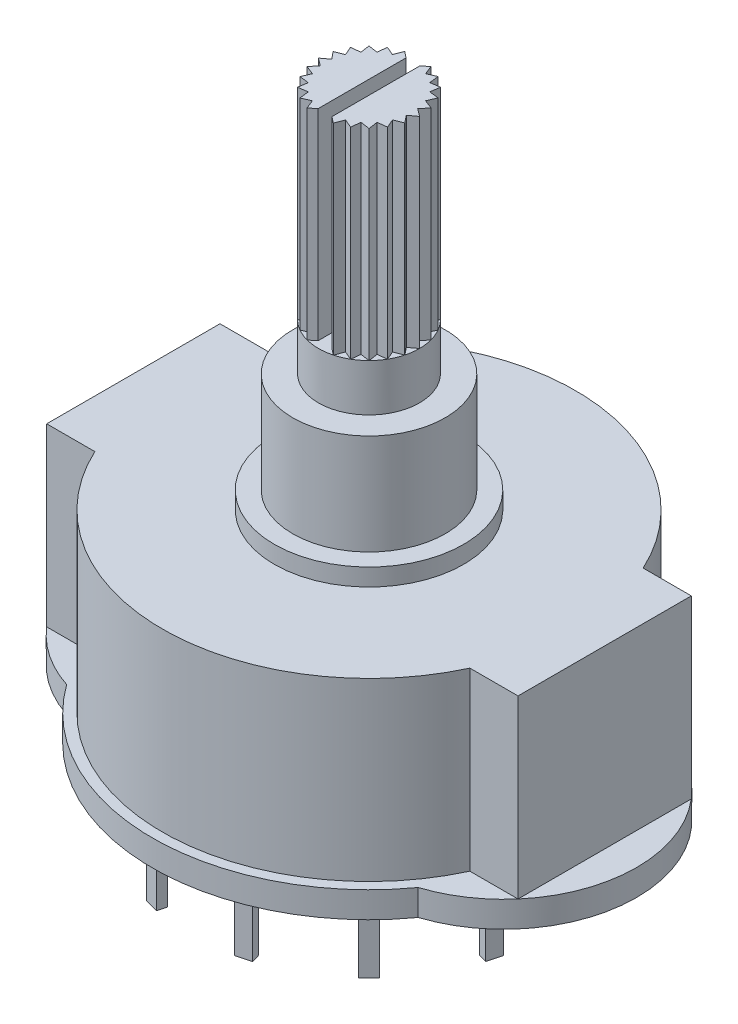
from build123d import *

# Parameters (mm, degrees)
BOSS_EXTRUDE1_DEPTH = 10.15
BOSS_EXTRUDE2_DEPTH = 1.5
SKETCH4_R           = 5.46
BOSS_EXTRUDE3_DEPTH = 1
SKETCH5_R           = 4.4
BOSS_EXTRUDE4_DEPTH = 5.8
SKETCH6_R           = 2.915
BOSS_EXTRUDE5_DEPTH = 14.32
BOSS_EXTRUDE6_DEPTH = 4.5
SKETCH8_W           = 0.5
SKETCH8_H           = 0.85
BOSS_EXTRUDE7_DEPTH = 4.5
SKETCH9_R           = 2.8
CUT_EXTRUDE1_DEPTH  = 4.5
CUT_EXTRUDE3_DEPTH  = 11.6
SKETCH10_W          = 0.8
SKETCH10_H          = 6.735502357
CUT_EXTRUDE2_DEPTH  = 11.6


with BuildPart() as part:
    # Sketch2 → Boss-Extrude1 (new body)
    with BuildSketch(Plane(origin=(0, 0, 0), x_dir=(1, 0, 0), z_dir=(0, 1, 0))):
        with BuildLine():
            Line((-13.6, 5), (-13.6, -5))
            Line((-13.6, -5), (-10.820646931, -5))
            ThreePointArc((-10.820646931, -5), (0, -11.92), (10.820646931, -5))
            Line((10.820646931, -5), (13.6, -5))
            Line((13.6, -5), (13.6, 5))
            Line((13.6, 5), (10.820646931, 5))
            ThreePointArc((10.820646931, 5), (0, 11.92), (-10.820646931, 5))
            Line((-10.820646931, 5), (-13.6, 5))
        make_face()
    extrude(amount=BOSS_EXTRUDE1_DEPTH)

    # Sketch3 → Boss-Extrude2 (add)
    with BuildSketch(Plane.XZ):
        with BuildLine():
            ThreePointArc((-10.142976429, -7.305479393), (0, -12.5), (10.142976429, -7.305479393))
            ThreePointArc((10.142976429, -7.305479393), (15.45, 0), (10.142976429, 7.305479393))
            ThreePointArc((10.142976429, 7.305479393), (0, 12.5), (-10.142976429, 7.305479393))
            ThreePointArc((-10.142976429, 7.305479393), (-15.45, 0), (-10.142976429, -7.305479393))
        make_face()
    extrude(amount=BOSS_EXTRUDE2_DEPTH)

    # Sketch4 → Boss-Extrude3 (add)
    with BuildSketch(Plane(origin=(0, 10.15, 0), x_dir=(1, 0, 0), z_dir=(0, 1, 0))):
        Circle(SKETCH4_R)
    extrude(amount=BOSS_EXTRUDE3_DEPTH)

    # Sketch5 → Boss-Extrude4 (add)
    with BuildSketch(Plane(origin=(0, 11.15, 0), x_dir=(1, 0, 0), z_dir=(0, 1, 0))):
        Circle(SKETCH5_R)
    extrude(amount=BOSS_EXTRUDE4_DEPTH)

    # Sketch6 → Boss-Extrude5 (add)
    with BuildSketch(Plane(origin=(0, 16.95, 0), x_dir=(1, 0, 0), z_dir=(0, 1, 0))):
        Circle(SKETCH6_R)
    extrude(amount=BOSS_EXTRUDE5_DEPTH)

    # Sketch7 → Boss-Extrude6 (add)
    with BuildSketch(Plane.XZ.offset(1.5)):
        Polygon((2.113087536, 9.528222971), (2.933883844, 9.307330641), (3.063820508, 9.790151999), (2.243024201, 10.011044329), align=None)
        Polygon((6.948038104, 7.548306607), (7.548422392, 6.946610084), (7.194483261, 6.593442855), (6.594098972, 7.195139378), align=None)
        Polygon((9.791330808, 3.063006225), (10.010430592, 2.241729606), (9.527326698, 2.11284738), (9.308226914, 2.934123999), align=None)
        Polygon((10.011044329, -2.243024201), (9.790151999, -3.063820508), (9.307330641, -2.933883844), (9.528222971, -2.113087536), align=None)
        Polygon((7.548306607, -6.948038104), (6.946610084, -7.548422392), (6.593442855, -7.194483261), (7.195139378, -6.594098972), align=None)
        Polygon((3.063006225, -9.791330808), (2.241729606, -10.010430592), (2.11284738, -9.527326698), (2.934123999, -9.308226914), align=None)
        Polygon((-2.243024201, -10.011044329), (-3.063820508, -9.790151999), (-2.933883844, -9.307330641), (-2.113087536, -9.528222971), align=None)
        Polygon((-6.948038104, -7.548306607), (-7.548422392, -6.946610084), (-7.194483261, -6.593442855), (-6.594098972, -7.195139378), align=None)
        Polygon((-9.791330808, -3.063006225), (-10.010430592, -2.241729606), (-9.527326698, -2.11284738), (-9.308226914, -2.934123999), align=None)
        Polygon((-10.011044329, 2.243024201), (-9.790151999, 3.063820508), (-9.307330641, 2.933883844), (-9.528222971, 2.113087536), align=None)
        Polygon((-7.548306607, 6.948038104), (-6.946610084, 7.548422392), (-6.593442855, 7.194483261), (-7.195139378, 6.594098972), align=None)
        Polygon((-3.063006225, 9.791330808), (-2.241729606, 10.010430592), (-2.11284738, 9.527326698), (-2.934123999, 9.308226914), align=None)
    extrude(amount=BOSS_EXTRUDE6_DEPTH)

    # Sketch8 → Boss-Extrude7 (add)
    with BuildSketch(Plane.XZ.offset(1.5)):
        with Locations((-6.15, 0)):
            Rectangle(SKETCH8_W, SKETCH8_H)
        with Locations((6.15, 0)):
            Rectangle(SKETCH8_W, SKETCH8_H)
    extrude(amount=BOSS_EXTRUDE7_DEPTH)

    # Sketch9 → Cut-Extrude1 (cut)
    with BuildSketch(Plane.XZ.offset(1.5)):
        Circle(SKETCH9_R)
    extrude(amount=-CUT_EXTRUDE1_DEPTH, mode=Mode.SUBTRACT)

    # Sketch11 → Cut-Extrude3 (cut)
    with BuildSketch(Plane(origin=(0, 31.27, 0), x_dir=(1, 0, 0), z_dir=(0, 1, 0))):
        with BuildLine():
            Line((-1.523472719, 1.982178316), (-1.461493827, 2.522153999))
            ThreePointArc((-1.461493827, 2.522153999), (-1.77636919, 2.311219916), (-2.061216267, 2.061216267))
            Line((-2.061216267, 2.061216267), (-1.523472719, 1.982178316))
        make_face()
        with BuildLine():
            Line((-0.958536146, 2.308940982), (-0.758913143, 2.814476122))
            ThreePointArc((-0.758913143, 2.814476122), (-1.117653146, 2.692225185), (-1.4575, 2.524464052))
            Line((-1.4575, 2.524464052), (-0.958536146, 2.308940982))
        make_face()
        with BuildLine():
            Line((-0.328276919, 2.478353136), (-0.004613782, 2.914996349))
            ThreePointArc((-0.004613782, 2.914996349), (-0.382770887, 2.889759756), (-0.754457516, 2.815673784))
            Line((-0.754457516, 2.815673784), (-0.328276919, 2.478353136))
        make_face()
        with BuildLine():
            ThreePointArc((0.75, 2.816864391), (0.378196575, 2.890361976), (0, 2.915))
            Line((0, 2.915), (0.324353838, 2.478869619))
            Line((0.324353838, 2.478869619), (0.75, 2.816864391))
        make_face()
        with BuildLine():
            ThreePointArc((1.453502522, 2.526767781), (1.113390566, 2.693990803), (0.754457516, 2.815673784))
            Line((0.754457516, 2.815673784), (0.954880417, 2.310455234))
            Line((0.954880417, 2.310455234), (1.453502522, 2.526767781))
        make_face()
        with BuildLine():
            ThreePointArc((2.057951249, 2.064476122), (1.77270883, 2.31402861), (1.4575, 2.524464052))
            Line((1.4575, 2.524464052), (1.520333473, 1.984587144))
            Line((1.520333473, 1.984587144), (2.057951249, 2.064476122))
        make_face()
        with BuildLine():
            ThreePointArc((2.522153999, 1.461493827), (2.311219916, 1.77636919), (2.061216267, 2.061216267))
            Line((2.061216267, 2.061216267), (1.982178316, 1.523472719))
            Line((1.982178316, 1.523472719), (2.522153999, 1.461493827))
        make_face()
        with BuildLine():
            ThreePointArc((2.814476122, 0.758913143), (2.692225185, 1.117653146), (2.524464052, 1.4575))
            Line((2.524464052, 1.4575), (2.308940982, 0.958536146))
            Line((2.308940982, 0.958536146), (2.814476122, 0.758913143))
        make_face()
        with BuildLine():
            ThreePointArc((2.914996349, 0.004613782), (2.889759756, 0.382770887), (2.815673784, 0.754457516))
            Line((2.815673784, 0.754457516), (2.478353136, 0.328276919))
            Line((2.478353136, 0.328276919), (2.914996349, 0.004613782))
        make_face()
        with BuildLine():
            ThreePointArc((2.816864391, -0.75), (2.890361976, -0.378196575), (2.915, 0))
            Line((2.915, 0), (2.478869619, -0.324353838))
            Line((2.478869619, -0.324353838), (2.816864391, -0.75))
        make_face()
        with BuildLine():
            ThreePointArc((2.526767781, -1.453502522), (2.693990803, -1.113390566), (2.815673784, -0.754457516))
            Line((2.815673784, -0.754457516), (2.310455234, -0.954880417))
            Line((2.310455234, -0.954880417), (2.526767781, -1.453502522))
        make_face()
        with BuildLine():
            ThreePointArc((2.064476122, -2.057951249), (2.31402861, -1.77270883), (2.524464052, -1.4575))
            Line((2.524464052, -1.4575), (1.984587144, -1.520333473))
            Line((1.984587144, -1.520333473), (2.064476122, -2.057951249))
        make_face()
        with BuildLine():
            ThreePointArc((1.461493827, -2.522153999), (1.77636919, -2.311219916), (2.061216267, -2.061216267))
            Line((2.061216267, -2.061216267), (1.523472719, -1.982178316))
            Line((1.523472719, -1.982178316), (1.461493827, -2.522153999))
        make_face()
        with BuildLine():
            ThreePointArc((0.758913143, -2.814476122), (1.117653146, -2.692225185), (1.4575, -2.524464052))
            Line((1.4575, -2.524464052), (0.958536146, -2.308940982))
            Line((0.958536146, -2.308940982), (0.758913143, -2.814476122))
        make_face()
        with BuildLine():
            ThreePointArc((0.004613782, -2.914996349), (0.382770887, -2.889759756), (0.754457516, -2.815673784))
            Line((0.754457516, -2.815673784), (0.328276919, -2.478353136))
            Line((0.328276919, -2.478353136), (0.004613782, -2.914996349))
        make_face()
        with BuildLine():
            Line((-0.324353838, -2.478869619), (-0.75, -2.816864391))
            ThreePointArc((-0.75, -2.816864391), (-0.378196575, -2.890361976), (0, -2.915))
            Line((0, -2.915), (-0.324353838, -2.478869619))
        make_face()
        with BuildLine():
            Line((-0.954880417, -2.310455234), (-1.453502522, -2.526767781))
            ThreePointArc((-1.453502522, -2.526767781), (-1.113390566, -2.693990803), (-0.754457516, -2.815673784))
            Line((-0.754457516, -2.815673784), (-0.954880417, -2.310455234))
        make_face()
        with BuildLine():
            Line((-1.520333473, -1.984587144), (-2.057951249, -2.064476122))
            ThreePointArc((-2.057951249, -2.064476122), (-1.77270883, -2.31402861), (-1.4575, -2.524464052))
            Line((-1.4575, -2.524464052), (-1.520333473, -1.984587144))
        make_face()
        with BuildLine():
            Line((-1.982178316, -1.523472719), (-2.522153999, -1.461493827))
            ThreePointArc((-2.522153999, -1.461493827), (-2.311219916, -1.77636919), (-2.061216267, -2.061216267))
            Line((-2.061216267, -2.061216267), (-1.982178316, -1.523472719))
        make_face()
        with BuildLine():
            Line((-2.308940982, -0.958536146), (-2.814476122, -0.758913143))
            ThreePointArc((-2.814476122, -0.758913143), (-2.692225185, -1.117653146), (-2.524464052, -1.4575))
            Line((-2.524464052, -1.4575), (-2.308940982, -0.958536146))
        make_face()
        with BuildLine():
            Line((-2.478353136, -0.328276919), (-2.914996349, -0.004613782))
            ThreePointArc((-2.914996349, -0.004613782), (-2.889759756, -0.382770887), (-2.815673784, -0.754457516))
            Line((-2.815673784, -0.754457516), (-2.478353136, -0.328276919))
        make_face()
        with BuildLine():
            Line((-2.478869619, 0.324353838), (-2.816864391, 0.75))
            ThreePointArc((-2.816864391, 0.75), (-2.890361976, 0.378196575), (-2.915, 0))
            Line((-2.915, 0), (-2.478869619, 0.324353838))
        make_face()
        with BuildLine():
            Line((-2.310455234, 0.954880417), (-2.526767781, 1.453502522))
            ThreePointArc((-2.526767781, 1.453502522), (-2.693990803, 1.113390566), (-2.815673784, 0.754457516))
            Line((-2.815673784, 0.754457516), (-2.310455234, 0.954880417))
        make_face()
        with BuildLine():
            Line((-1.984587144, 1.520333473), (-2.064476122, 2.057951249))
            ThreePointArc((-2.064476122, 2.057951249), (-2.31402861, 1.77270883), (-2.524464052, 1.4575))
            Line((-2.524464052, 1.4575), (-1.984587144, 1.520333473))
        make_face()
    extrude(amount=-CUT_EXTRUDE3_DEPTH, mode=Mode.SUBTRACT)

    # Sketch10 → Cut-Extrude2 (cut)
    with BuildSketch(Plane(origin=(0, 31.27, 0), x_dir=(1, 0, 0), z_dir=(0, 1, 0))):
        with Locations((0, 0.023459837)):
            Rectangle(SKETCH10_W, SKETCH10_H)
    extrude(amount=-CUT_EXTRUDE2_DEPTH, mode=Mode.SUBTRACT)


solid = part.part
